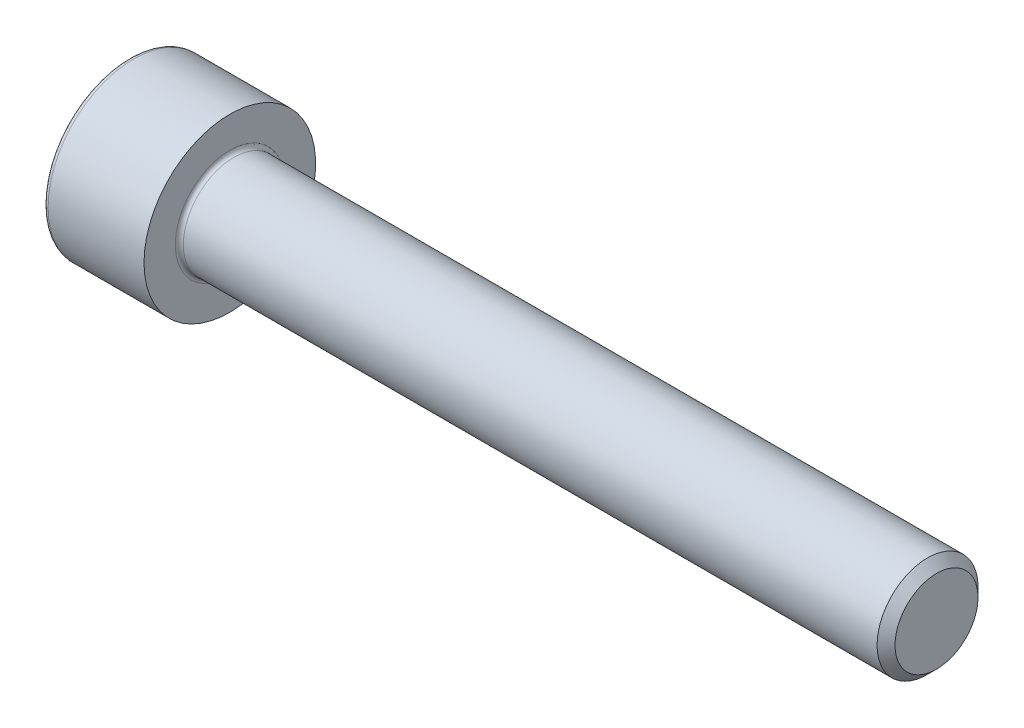
from build123d import *

# Parameters (mm, degrees)
FILLET1_R   = 0.2
FILLET2_R   = 0.25
HEX_2_DEPTH = 2.5


with BuildPart() as part:
    # BodySke → Base-Revolve (revolve)
    with BuildSketch(Plane.XY):
        Polygon((0, 0), (0, 4.25), (5, 4.25), (5, 2.5), (39.555, 2.5), (40, 2.055), (40, 0), align=None)
    revolve(axis=Axis((-31.75, 0, 0), (1, 0, 0)))

    # Fillet1
    fillet1_edges = [part.edges().sort_by_distance(p)[0] for p in [
        (5, -2.5, 0),
    ]]
    fillet(fillet1_edges, radius=FILLET1_R)

    # Fillet2
    fillet2_edges = [part.edges().sort_by_distance(p)[0] for p in [
        (0, -4.25, 0),
    ]]
    fillet(fillet2_edges, radius=FILLET2_R)

    # Sketch2 → Hex-PreBroach (revolve, cut)
    with BuildSketch(Plane.XY):
        Polygon((0, 2.042), (2.5, 2.042), (3.67894925, 0), (0, 0), align=None)
    revolve(axis=Axis((0, 0, 0), (1, 0, 0)), mode=Mode.SUBTRACT)

    # Sketch3 → Hex 2 (cut)
    with BuildSketch(Plane(origin=(0, 0, 0), x_dir=(0, 0.5, 0.866025404), z_dir=(-1, 0, 0))):
        Polygon((1.17894925, 2.042), (-1.17894925, 2.042), (-2.357898499, 0), (-1.17894925, -2.042), (1.17894925, -2.042), (2.357898499, 0), align=None)
    extrude(amount=-HEX_2_DEPTH, mode=Mode.SUBTRACT)


solid = part.part
